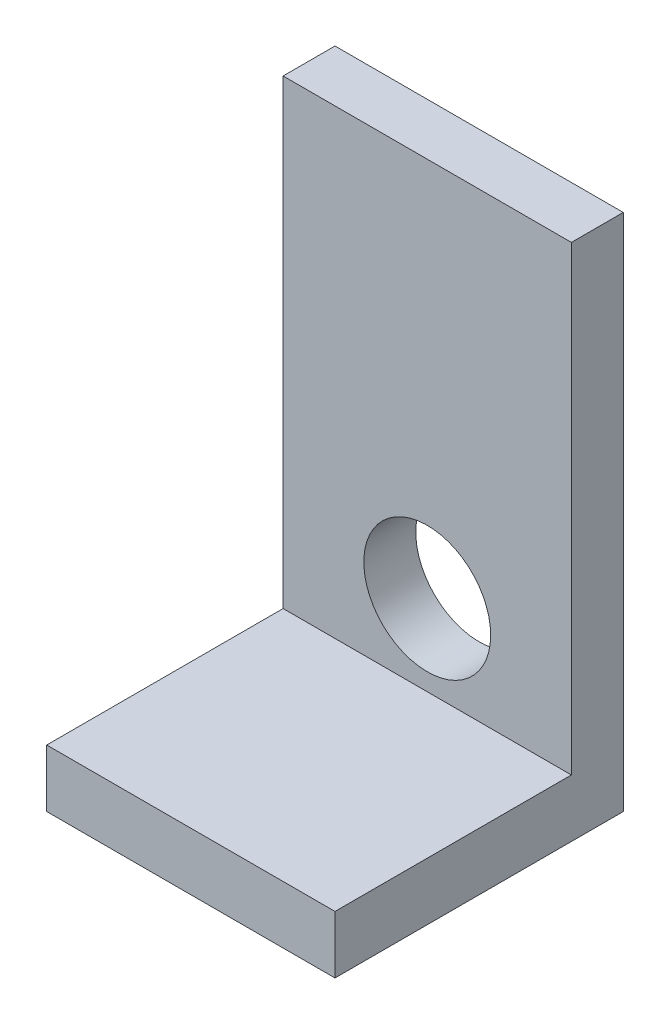
from build123d import *

# Parameters (mm, degrees)
SKETCH1_W           = 6.35
SKETCH1_H           = 6.35
BOSS_EXTRUDE1_DEPTH = 1.27
SKETCH2_W           = 6.35
SKETCH2_H           = 1.143
BOSS_EXTRUDE2_DEPTH = 10.16
CUT_EXTRUDE1_REACH  = 3.143
SKETCH4_R           = 1.397


with BuildPart() as part:
    # Sketch1 → Boss-Extrude1 (new body)
    with BuildSketch(Plane(origin=(0, 0, 0), x_dir=(1, 0, 0), z_dir=(0, 1, 0))):
        Rectangle(SKETCH1_W, SKETCH1_H)
    extrude(amount=BOSS_EXTRUDE1_DEPTH)

    # Sketch2 → Boss-Extrude2 (add)
    with BuildSketch(Plane(origin=(0, 1.27, 0), x_dir=(1, 0, 0), z_dir=(0, 1, 0))):
        with Locations((0, 2.6035)):
            Rectangle(SKETCH2_W, SKETCH2_H)
    extrude(amount=BOSS_EXTRUDE2_DEPTH)

    # Sketch4 → Cut-Extrude1 (cut, up to next)
    with BuildSketch(Plane.XY.offset(-2.032), mode=Mode.PRIVATE) as cut_extrude1_sk1:
        with Locations((0, 3.048)):
            Circle(SKETCH4_R)
    cut_extrude1_tool1 = extrude(cut_extrude1_sk1.sketch, amount=-CUT_EXTRUDE1_REACH, mode=Mode.PRIVATE) & part.part
    add(cut_extrude1_tool1.solids().sort_by_distance((0, 3.048, -2.032))[0], mode=Mode.SUBTRACT)


solid = part.part
